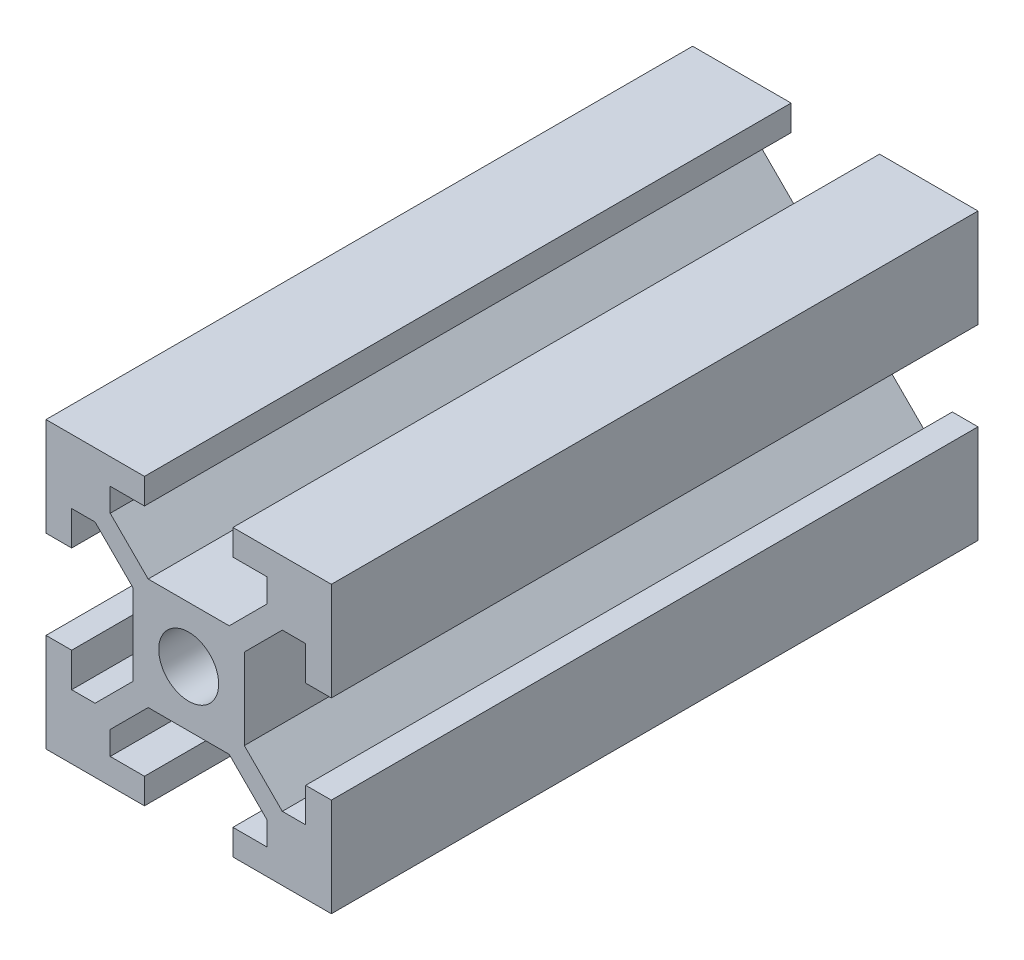
from build123d import *

# Parameters (mm, degrees)
BOSS_EXTRUDE1_DEPTH = 45.32
SKETCH2_R           = 2.1
CUT_EXTRUDE1_DEPTH  = 46.32
SKETCH3_R           = 2.1
CUT_EXTRUDE2_DEPTH  = 14.900660172


with BuildPart() as part:
    # Sketch1 → Boss-Extrude1 (new body)
    with BuildSketch(Plane.XY):
        Polygon((-3.1, 10), (-3.1, 8.200660172), (-5.5, 8.200660172), (-5.5, 6.560660172), (-2.84, 3.900660172), (2.84, 3.900660172), (5.5, 6.560660172), (5.5, 8.200660172), (3.1, 8.200660172), (3.1, 10), (10, 10), (10, 3.1), (8.200660172, 3.1), (8.200660172, 5.5), (6.560660172, 5.5), (3.900660172, 2.84), (3.900660172, -2.84), (6.560660172, -5.5), (8.200660172, -5.5), (8.200660172, -3.1), (10, -3.1), (10, -10), (3.1, -10), (3.1, -8.200660172), (5.5, -8.200660172), (5.5, -6.560660172), (2.84, -3.900660172), (-2.84, -3.900660172), (-5.5, -6.560660172), (-5.5, -8.200660172), (-3.1, -8.200660172), (-3.1, -10), (-10, -10), (-10, -3.1), (-8.200660172, -3.1), (-8.200660172, -5.5), (-6.560660172, -5.5), (-3.900660172, -2.84), (-3.900660172, 2.84), (-6.560660172, 5.5), (-8.200660172, 5.5), (-8.200660172, 3.1), (-10, 3.1), (-10, 10), align=None)
    extrude(amount=BOSS_EXTRUDE1_DEPTH)

    # Sketch2 → Cut-Extrude1 (cut, through all)
    with BuildSketch(Plane.XY.offset(45.32)):
        Circle(SKETCH2_R)
    extrude(amount=-CUT_EXTRUDE1_DEPTH, mode=Mode.SUBTRACT)

    # Sketch3 → Cut-Extrude2 (cut, through all)
    with BuildSketch(Plane(origin=(0, 3.900660172, 0), x_dir=(1, 0, 0), z_dir=(0, 1, 0))):
        with Locations((0, -22.66)):
            Circle(SKETCH3_R)
    extrude(amount=-CUT_EXTRUDE2_DEPTH, mode=Mode.SUBTRACT)


solid = part.part
